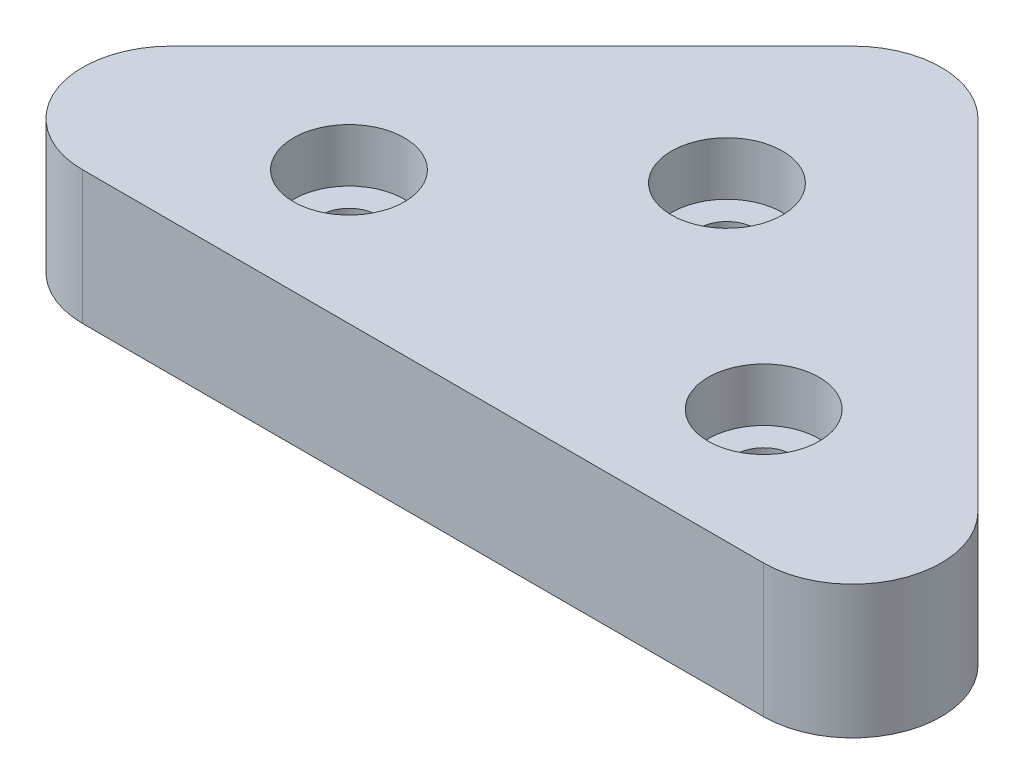
from build123d import *

# Parameters (mm, degrees)
BOSS_EXTRUDE1_DEPTH                            = 3.81
FILLET1_R                                      = 2.54
CBORE_FOR_0_SOCKET_HEAD_CAP_SCREW1_D           = 1.6129
CBORE_FOR_0_SOCKET_HEAD_CAP_SCREW1_DEPTH       = 3.302
CBORE_FOR_0_SOCKET_HEAD_CAP_SCREW1_CBORE_D     = 3.175
CBORE_FOR_0_SOCKET_HEAD_CAP_SCREW1_CBORE_DEPTH = 1.524
CBORE_FOR_0_SOCKET_HEAD_CAP_SCREW1_TIP         = 0.484564046


with BuildPart() as part:
    # Sketch2 → Boss-Extrude1 (new body)
    with BuildSketch(Plane(origin=(0, 0, 0), x_dir=(1, 0, 0), z_dir=(0, 1, 0))):
        Polygon((31.75, 0), (0, 0), (15.875, 15.875), align=None)
    extrude(amount=BOSS_EXTRUDE1_DEPTH)

    # Fillet1
    fillet1_edges = [part.edges().sort_by_distance(p)[0] for p in [
        (0, 1.905, 0),
        (15.875, 1.905, -15.875),
        (31.75, 1.905, 0),
    ]]
    fillet(fillet1_edges, radius=FILLET1_R)

    # CBORE for #0 Socket Head Cap Screw1
    with Locations(Plane(origin=(0, 3.81, 0), x_dir=(1, 0, 0), z_dir=(0, 1, 0))):
        with Locations((9.942102448, 3.81), (15.677428144, 8.89), (21.807897552, 3.81)):
            CounterBoreHole(CBORE_FOR_0_SOCKET_HEAD_CAP_SCREW1_D / 2, CBORE_FOR_0_SOCKET_HEAD_CAP_SCREW1_CBORE_D / 2, CBORE_FOR_0_SOCKET_HEAD_CAP_SCREW1_CBORE_DEPTH, depth=CBORE_FOR_0_SOCKET_HEAD_CAP_SCREW1_DEPTH)
            with Locations((0, 0, -(CBORE_FOR_0_SOCKET_HEAD_CAP_SCREW1_DEPTH + CBORE_FOR_0_SOCKET_HEAD_CAP_SCREW1_TIP / 2))):  # 118° drill point
                Cone(0, CBORE_FOR_0_SOCKET_HEAD_CAP_SCREW1_D / 2, CBORE_FOR_0_SOCKET_HEAD_CAP_SCREW1_TIP, mode=Mode.SUBTRACT)


solid = part.part
